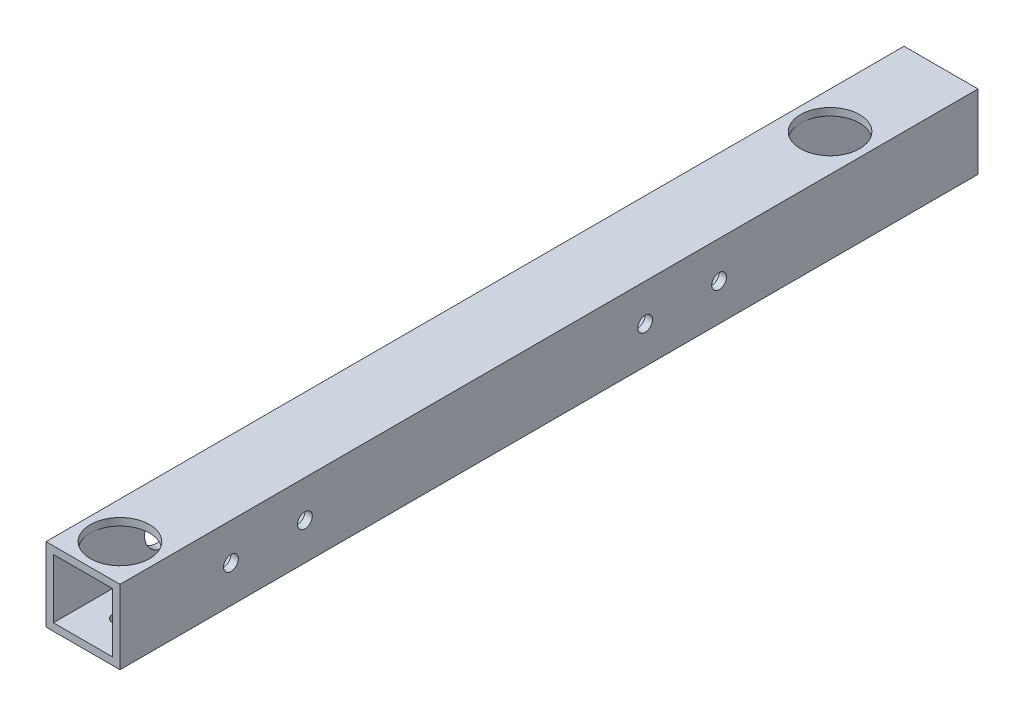
from build123d import *

# Parameters (mm, degrees)
SKETCH_1_W           = 15
SKETCH_1_H           = 15
SKETCH_1_W_2         = 12
SKETCH_1_H_2         = 12
EXTRUDE_2_DEPTH      = 174
CUT_EXTRUDE_1_DEPTH  = 10
SKETCH_3_R           = 1.5
CUT_EXTRUDE_2_DEPTH  = 10
SKETCH_6_R           = 4
CUT_EXTRUDE_4_DEPTH  = 10
SKETCH_7_R           = 1.5
CUT_EXTRUDE_5_DEPTH  = 10
SKETCH_8_R           = 4
CUT_EXTRUDE_6_DEPTH  = 10
SKETCH_10_R          = 1.5
CUT_EXTRUDE_9_DEPTH  = 10
SKETCH_12_R          = 4
CUT_EXTRUDE_10_DEPTH = 10
SKETCH_13_R          = 1.5
CUT_EXTRUDE_11_DEPTH = 10
SKETCH_14_R          = 4
CUT_EXTRUDE_12_DEPTH = 10
SKETCH_15_R          = 1.5
CUT_EXTRUDE_13_DEPTH = 10
SKETCH_16_R          = 6
CUT_EXTRUDE_14_DEPTH = 10
SKETCH_17_R          = 1.5
CUT_EXTRUDE_15_DEPTH = 10
SKETCH_18_R          = 6
CUT_EXTRUDE_16_DEPTH = 10
SKETCH_19_R          = 4
CUT_EXTRUDE_17_DEPTH = 10
SKETCH_20_R          = 1.5
CUT_EXTRUDE_18_DEPTH = 10
SKETCH_21_R          = 1.5
CUT_EXTRUDE_19_DEPTH = 10
SKETCH_22_R          = 4
CUT_EXTRUDE_20_DEPTH = 10


with BuildPart() as part:
    # ｽｹｯﾁ1 → ﾎﾞｽ - 押し出し2 (new body)
    with BuildSketch(Plane.XY):
        with Locations((0.489915859, 0.232626086)):
            Rectangle(SKETCH_1_W, SKETCH_1_H)
        with Locations((0.489915859, 0.232626086)):
            Rectangle(SKETCH_1_W_2, SKETCH_1_H_2, mode=Mode.SUBTRACT)
    extrude(amount=EXTRUDE_2_DEPTH)

    # ｽｹｯﾁ2 → ｶｯﾄ - 押し出し1 (cut)
    with BuildSketch(Plane(origin=(0, -7.267373914, 0), x_dir=(-1, 0, 0), z_dir=(0, -1, 0))):
        with BuildLine():
            ThreePointArc((1.010084141, -7.5), (0.570744313, -6.439339828), (-0.489915859, -6))
            Line((-0.489915859, -6), (-0.489915859, -7.5))
            Line((-0.489915859, -7.5), (1.010084141, -7.5))
        make_face()
        with BuildLine():
            Line((-0.489915859, -7.5), (-0.489915859, -6))
            ThreePointArc((-0.489915859, -6), (-1.550576031, -8.560660172), (1.010084141, -7.5))
            Line((1.010084141, -7.5), (-0.489915859, -7.5))
        make_face()
    extrude(amount=-CUT_EXTRUDE_1_DEPTH, mode=Mode.SUBTRACT)

    # ｽｹｯﾁ3 → ｶｯﾄ - 押し出し2 (cut)
    with BuildSketch(Plane(origin=(7.989915859, 0, 0), x_dir=(0, 0, -1), z_dir=(1, 0, 0))):
        with Locations((-52.5, 0.232626086)):
            Circle(SKETCH_3_R)
    extrude(amount=-CUT_EXTRUDE_2_DEPTH, mode=Mode.SUBTRACT)

    # ｽｹｯﾁ6 → ｶｯﾄ - 押し出し4 (cut)
    with BuildSketch(Plane.ZY.offset(7.010084141)):
        with Locations((52.5, 0.232626086)):
            Circle(SKETCH_6_R)
    extrude(amount=-CUT_EXTRUDE_4_DEPTH, mode=Mode.SUBTRACT)

    # ｽｹｯﾁ7 → ｶｯﾄ - 押し出し5 (cut)
    with BuildSketch(Plane(origin=(7.989915859, 0, 0), x_dir=(0, 0, -1), z_dir=(1, 0, 0))):
        with Locations((-151.5, 0.232626086)):
            Circle(SKETCH_7_R)
    extrude(amount=-CUT_EXTRUDE_5_DEPTH, mode=Mode.SUBTRACT)

    # ｽｹｯﾁ8 → ｶｯﾄ - 押し出し6 (cut)
    with BuildSketch(Plane.ZY.offset(7.010084141)):
        with Locations((151.5, 0.232626086)):
            Circle(SKETCH_8_R)
    extrude(amount=-CUT_EXTRUDE_6_DEPTH, mode=Mode.SUBTRACT)

    # ｽｹｯﾁ10 → ｶｯﾄ - 押し出し9 (cut)
    with BuildSketch(Plane.ZY.offset(7.010084141)):
        with Locations((86.8, 0.232626086)):
            Circle(SKETCH_10_R)
    extrude(amount=-CUT_EXTRUDE_9_DEPTH, mode=Mode.SUBTRACT)

    # ｽｹｯﾁ12 → ｶｯﾄ - 押し出し10 (cut)
    with BuildSketch(Plane.XZ.offset(7.267373914)):
        with Locations((0.489915859, 86.8)):
            Circle(SKETCH_12_R)
    extrude(amount=-CUT_EXTRUDE_10_DEPTH, mode=Mode.SUBTRACT)

    # ｽｹｯﾁ13 → ｶｯﾄ - 押し出し11 (cut)
    with BuildSketch(Plane.ZY.offset(7.010084141)):
        with Locations((116.8, 0.232626086)):
            Circle(SKETCH_13_R)
    extrude(amount=-CUT_EXTRUDE_11_DEPTH, mode=Mode.SUBTRACT)

    # ｽｹｯﾁ14 → ｶｯﾄ - 押し出し12 (cut)
    with BuildSketch(Plane.XZ.offset(7.267373914)):
        with Locations((0.489915859, 116.8)):
            Circle(SKETCH_14_R)
    extrude(amount=-CUT_EXTRUDE_12_DEPTH, mode=Mode.SUBTRACT)

    # ｽｹｯﾁ15 → ｶｯﾄ - 押し出し13 (cut)
    with BuildSketch(Plane.XZ.offset(7.267373914)):
        with Locations((0.489915859, 22.5)):
            Circle(SKETCH_15_R)
    extrude(amount=-CUT_EXTRUDE_13_DEPTH, mode=Mode.SUBTRACT)

    # ｽｹｯﾁ16 → ｶｯﾄ - 押し出し14 (cut)
    with BuildSketch(Plane(origin=(0, 7.732626086, 0), x_dir=(1, 0, 0), z_dir=(0, 1, 0))):
        with Locations((0.489915859, -22.5)):
            Circle(SKETCH_16_R)
    extrude(amount=-CUT_EXTRUDE_14_DEPTH, mode=Mode.SUBTRACT)

    # ｽｹｯﾁ17 → ｶｯﾄ - 押し出し15 (cut)
    with BuildSketch(Plane.XZ.offset(7.267373914)):
        with Locations((0.489915859, 166.5)):
            Circle(SKETCH_17_R)
    extrude(amount=-CUT_EXTRUDE_15_DEPTH, mode=Mode.SUBTRACT)

    # ｽｹｯﾁ18 → ｶｯﾄ - 押し出し16 (cut)
    with BuildSketch(Plane(origin=(0, 7.732626086, 0), x_dir=(1, 0, 0), z_dir=(0, 1, 0))):
        with Locations((0.489915859, -166.5)):
            Circle(SKETCH_18_R)
    extrude(amount=-CUT_EXTRUDE_16_DEPTH, mode=Mode.SUBTRACT)

    # ｽｹｯﾁ19 → ｶｯﾄ - 押し出し17 (cut)
    with BuildSketch(Plane.ZY.offset(7.010084141)):
        with Locations((67.5, 0.232626086)):
            Circle(SKETCH_19_R)
    extrude(amount=-CUT_EXTRUDE_17_DEPTH, mode=Mode.SUBTRACT)

    # ｽｹｯﾁ20 → ｶｯﾄ - 押し出し18 (cut)
    with BuildSketch(Plane(origin=(7.989915859, 0, 0), x_dir=(0, 0, -1), z_dir=(1, 0, 0))):
        with Locations((-67.5, 0.232626086)):
            Circle(SKETCH_20_R)
    extrude(amount=-CUT_EXTRUDE_18_DEPTH, mode=Mode.SUBTRACT)

    # ｽｹｯﾁ21 → ｶｯﾄ - 押し出し19 (cut)
    with BuildSketch(Plane(origin=(7.989915859, 0, 0), x_dir=(0, 0, -1), z_dir=(1, 0, 0))):
        with Locations((-136.5, 0.232626086)):
            Circle(SKETCH_21_R)
    extrude(amount=-CUT_EXTRUDE_19_DEPTH, mode=Mode.SUBTRACT)

    # ｽｹｯﾁ22 → ｶｯﾄ - 押し出し20 (cut)
    with BuildSketch(Plane.ZY.offset(7.010084141)):
        with Locations((136.5, 0.232626086)):
            Circle(SKETCH_22_R)
    extrude(amount=-CUT_EXTRUDE_20_DEPTH, mode=Mode.SUBTRACT)


solid = part.part
